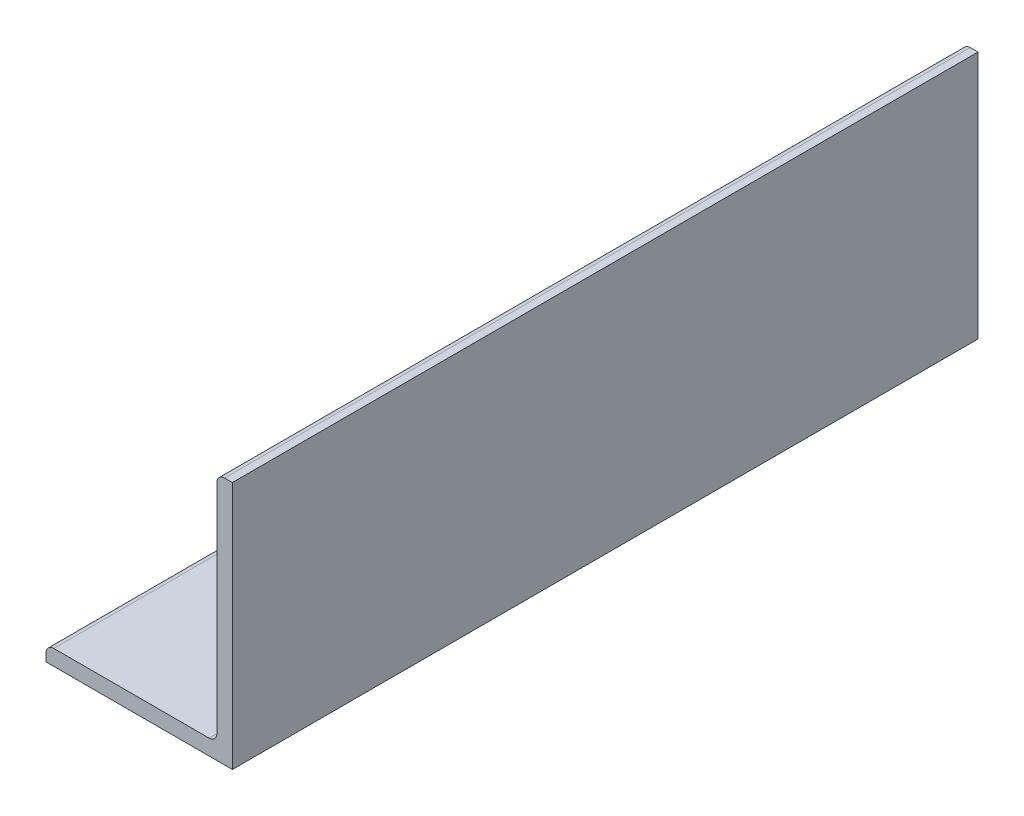
from build123d import *

# Parameters (mm, degrees)
BOSS_EXTRUDE1_DEPTH = 152.4


with BuildPart() as part:
    # Sketch2 → Boss-Extrude1 (new body, symmetric)
    with BuildSketch(Plane.XY):
        with BuildLine():
            Line((-38.1, 0), (38.1, 0))
            Line((38.1, 0), (38.1, 101.6))
            Line((38.1, 101.6), (34.925, 101.6))
            ThreePointArc((34.925, 101.6), (32.67993597, 100.67006403), (31.75, 98.425))
            Line((31.75, 98.425), (31.75, 9.525))
            ThreePointArc((31.75, 9.525), (30.82006403, 7.27993597), (28.575, 6.35))
            Line((28.575, 6.35), (-34.925, 6.35))
            ThreePointArc((-34.925, 6.35), (-37.17006403, 5.42006403), (-38.1, 3.175))
            Line((-38.1, 3.175), (-38.1, 0))
        make_face()
    extrude(amount=BOSS_EXTRUDE1_DEPTH, both=True)


solid = part.part
